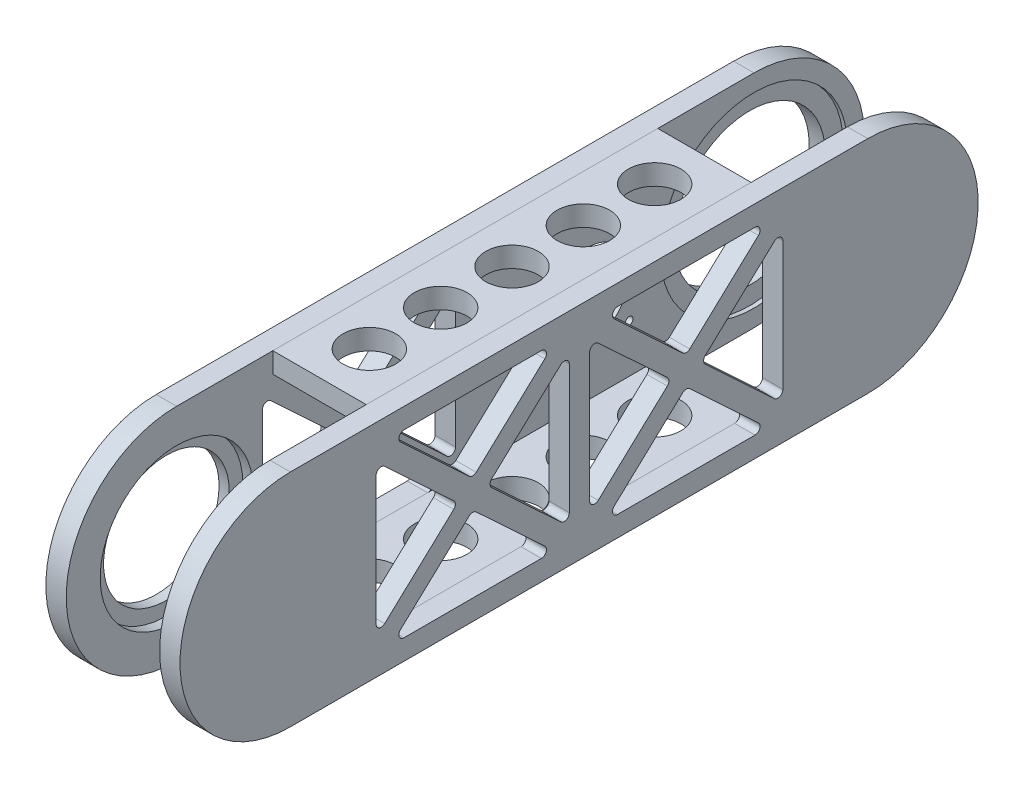
from build123d import *

# Parameters (mm, degrees)
PLATE_REFS_R                    = 44.5
PLATE_REFS_R_2                  = 15
PLATE_REFS_R_3                  = 45
PLATE_REFS_R_4                  = 37
PLATE_REFS_R_5                  = 55
PLATE_SHAPE_DEPTH               = 12
SHOULDER_GEAR_SLOT_START        = 12
PLATE_REFS_4_R                  = 55
PLATE_REFS_4_R_2                = 44.5
SHOULDER_GEAR_SLOT_DEPTH        = 2.5
ELBOW_GEAR_SLOT_START           = 12
PLATE_REFS_5_R                  = 45
ELBOW_GEAR_SLOT_DEPTH           = 6
SKETCH2_R                       = 25
SKETCH2_R_2                     = 2.25
J3_MOTOR_1_DEPTH                = 1
J3_MOTOR_1_DEPTH_BACK           = 13
SKETCH2_3_W                     = 70
SKETCH2_3_H                     = 70
SKETCH2_3_R                     = 25
SKETCH2_3_R_2                   = 2.25
J3_MOTOR_2_DEPTH                = 1
J3_MOTOR_2_DEPTH_BACK           = 6
FILLET1_R                       = 6
TOP_PLATE_START                 = 67
SKETCH3_W                       = 12
SKETCH3_H                       = 226.666666666
TOP_PLATE_DEPTH                 = 55
SIDE_PLATE_2_START              = 67
SIDE_PLATE_2_DEPTH              = 12
SKETCH4_R                       = 14
SIDE_PLATE_BEARING_MOUNTS_DEPTH = 8
PLATE_REFS_7_R                  = 37
CUT_EXTRUDE3_DEPTH              = 8
CUT_EXTRUDE4_DEPTH              = 1
CUT_EXTRUDE4_DEPTH_BACK         = 80
CUT_EXTRUDE5_DEPTH              = 1
CUT_EXTRUDE5_DEPTH_BACK         = 20
SKETCH8_R                       = 15.5
CUT_EXTRUDE6_DEPTH              = 1
CUT_EXTRUDE6_DEPTH_BACK         = 131


with BuildPart() as part:
    # Plate_refs → Plate_shape (new body)
    with BuildSketch(Plane.YZ):
        with BuildLine():
            Line((65, 340), (65, 0))
            ThreePointArc((65, 0), (0, -65), (-65, 0))
            Line((-65, 0), (-65, 340))
            ThreePointArc((-65, 340), (0, 405), (65, 340))
        make_face()
        Circle(PLATE_REFS_R, mode=Mode.SUBTRACT)
        with Locations((0, 340)):
            Circle(PLATE_REFS_R_2, mode=Mode.SUBTRACT)
        with Locations((0, 340)):
            Circle(PLATE_REFS_R_3)
        with Locations((0, 340)):
            Circle(PLATE_REFS_R_4, mode=Mode.SUBTRACT)
        with Locations((0, 340)):
            Circle(PLATE_REFS_R_4)
        with Locations((0, 340)):
            Circle(PLATE_REFS_R_2, mode=Mode.SUBTRACT)
        Circle(PLATE_REFS_R_5)
        Circle(PLATE_REFS_R, mode=Mode.SUBTRACT)
    extrude(amount=PLATE_SHAPE_DEPTH)

    # Plate_refs_4 → Shoulder_gear_slot (cut)
    with BuildSketch(Plane.YZ.offset(SHOULDER_GEAR_SLOT_START)):
        Circle(PLATE_REFS_4_R)
        Circle(PLATE_REFS_4_R_2, mode=Mode.SUBTRACT)
    extrude(amount=-SHOULDER_GEAR_SLOT_DEPTH, mode=Mode.SUBTRACT)

    # Plate_refs_5 → Elbow_gear_slot (cut)
    with BuildSketch(Plane.YZ.offset(ELBOW_GEAR_SLOT_START)):
        with Locations((0, 340)):
            Circle(PLATE_REFS_5_R)
    extrude(amount=-ELBOW_GEAR_SLOT_DEPTH, mode=Mode.SUBTRACT)

    # Sketch2 → J3_motor_1 (cut, two sides)
    with BuildSketch(Plane(origin=(0, 0, 0), x_dir=(0, -1, 0), z_dir=(-1, 0, 0))) as j3_motor_1_sk:
        with Locations((0, 98.247814675)):
            Circle(SKETCH2_R)
        with Locations((-24.748737342, 122.996552017)):
            Circle(SKETCH2_R_2)
        with Locations((24.748737342, 73.499077334)):
            Circle(SKETCH2_R_2)
        with Locations((24.748737342, 122.996552017)):
            Circle(SKETCH2_R_2)
        with Locations((-24.748737342, 73.499077334)):
            Circle(SKETCH2_R_2)
    extrude(amount=J3_MOTOR_1_DEPTH, mode=Mode.SUBTRACT)
    extrude(j3_motor_1_sk.sketch, amount=-J3_MOTOR_1_DEPTH_BACK, mode=Mode.SUBTRACT)

    # Sketch2_3 → J3_motor_2 (cut, two sides)
    with BuildSketch(Plane(origin=(0, 0, 0), x_dir=(0, -1, 0), z_dir=(-1, 0, 0))) as j3_motor_2_sk:
        with Locations((0, 98.247814675)):
            Rectangle(SKETCH2_3_W, SKETCH2_3_H)
        with Locations((0, 98.247814675)):
            Circle(SKETCH2_3_R, mode=Mode.SUBTRACT)
        with Locations((24.748737342, 122.996552017)):
            Circle(SKETCH2_3_R_2, mode=Mode.SUBTRACT)
        with Locations((24.748737342, 73.499077334)):
            Circle(SKETCH2_3_R_2, mode=Mode.SUBTRACT)
        with Locations((-24.748737342, 73.499077334)):
            Circle(SKETCH2_3_R_2, mode=Mode.SUBTRACT)
        with Locations((-24.748737342, 122.996552017)):
            Circle(SKETCH2_3_R_2, mode=Mode.SUBTRACT)
    extrude(amount=J3_MOTOR_2_DEPTH, mode=Mode.SUBTRACT)
    extrude(j3_motor_2_sk.sketch, amount=-J3_MOTOR_2_DEPTH_BACK, mode=Mode.SUBTRACT)

    # Fillet1
    fillet1_edges = [part.edges().sort_by_distance(p)[0] for p in [
        (3, -35, 63.247814675),
        (3, -35, 133.247814675),
        (3, 35, 133.247814675),
        (3, 35, 63.247814675),
    ]]
    fillet(fillet1_edges, radius=FILLET1_R)

    # Plate_refs_7 → Cut-Extrude3 (cut)
    with BuildSketch(Plane.YZ):
        with Locations((0, 340)):
            Circle(PLATE_REFS_7_R)
    extrude(amount=CUT_EXTRUDE3_DEPTH, mode=Mode.SUBTRACT)


with BuildPart() as body_2:
    # Sketch3 → Top_plate (new body)
    with BuildSketch(Plane.YZ.offset(TOP_PLATE_START)):
        with Locations((-59, 170)):
            Rectangle(SKETCH3_W, SKETCH3_H)
    extrude(amount=-TOP_PLATE_DEPTH)


with BuildPart() as body_3:
    # Bottom_plate: mirrored copy
    add(body_2.part.mirror(Plane.ZX))


with BuildPart() as body_4:
    # Plate_refs_6 → Side_plate_2 (new body)
    with BuildSketch(Plane.YZ.offset(SIDE_PLATE_2_START)):
        with BuildLine():
            Line((-65, 340), (-65, 0))
            ThreePointArc((-65, 0), (0, -65), (65, 0))
            Line((65, 0), (65, 340))
            ThreePointArc((65, 340), (0, 405), (-65, 340))
        make_face()
    extrude(amount=SIDE_PLATE_2_DEPTH)

    # Sketch4 → Side_plate_bearing_mounts (cut)
    with BuildSketch(Plane(origin=(67, 0, 0), x_dir=(0, -1, 0), z_dir=(-1, 0, 0))):
        with Locations((0, 340)):
            Circle(SKETCH4_R)
        Circle(SKETCH4_R)
    extrude(amount=-SIDE_PLATE_BEARING_MOUNTS_DEPTH, mode=Mode.SUBTRACT)


with BuildPart() as cut_extrude4_tool:
    # Sketch5 → Cut-Extrude4 (new body, two sides)
    with BuildSketch(Plane(origin=(0, 0, 0), x_dir=(0, -1, 0), z_dir=(-1, 0, 0))) as cut_extrude4_sk:
        with BuildLine():
            Line((-10.106298461, 234.693116547), (-47.805093136, 275.153651137))
            ThreePointArc((-47.805093136, 275.153651137), (-51.098926615, 275.900043345), (-53, 273.108563398))
            Line((-53, 273.108563398), (-53, 192.187494218))
            ThreePointArc((-53, 192.187494218), (-51.098926615, 189.396014271), (-47.805093136, 190.142406479))
            Line((-47.805093136, 190.142406479), (-21.507545379, 218.366461116))
            Line((-21.507545379, 218.366461116), (-10.106298461, 230.602941069))
            ThreePointArc((-10.106298461, 230.602941069), (-9.301205324, 232.648028808), (-10.106298461, 234.693116547))
        make_face()
        with BuildLine():
            ThreePointArc((2.194906864, 243.80530862), (0, 242.850396359), (-2.194906864, 243.80530862))
            Line((-2.194906864, 243.80530862), (-40.098474408, 284.485617338))
            ThreePointArc((-40.098474408, 284.485617338), (-40.654500406, 287.727521016), (-37.903567544, 289.530705077))
            Line((-37.903567544, 289.530705077), (37.903567544, 289.530705077))
            ThreePointArc((37.903567544, 289.530705077), (40.654500406, 287.727521016), (40.098474408, 284.485617338))
            Line((40.098474408, 284.485617338), (2.194906864, 243.80530862))
        make_face()
        with BuildLine():
            ThreePointArc((47.805093136, 275.153651137), (51.098926615, 275.900043345), (53, 273.108563398))
            Line((53, 273.108563398), (53, 192.187494218))
            ThreePointArc((53, 192.187494218), (51.098926615, 189.396014271), (47.805093136, 190.142406479))
            Line((47.805093136, 190.142406479), (10.106298461, 230.602941069))
            ThreePointArc((10.106298461, 230.602941069), (9.301205324, 232.648028808), (10.106298461, 234.693116547))
            Line((10.106298461, 234.693116547), (47.805093136, 275.153651137))
        make_face()
        with BuildLine():
            ThreePointArc((40.098474408, 180.810440277), (40.654500406, 177.5685366), (37.903567544, 175.765352539))
            Line((37.903567544, 175.765352539), (-37.903567544, 175.765352539))
            ThreePointArc((-37.903567544, 175.765352539), (-40.654500406, 177.5685366), (-40.098474408, 180.810440277))
            Line((-40.098474408, 180.810440277), (-2.194906864, 221.490748996))
            ThreePointArc((-2.194906864, 221.490748996), (0, 222.445661257), (2.194906864, 221.490748996))
            Line((2.194906864, 221.490748996), (40.098474408, 180.810440277))
        make_face()
    extrude(amount=CUT_EXTRUDE4_DEPTH)
    extrude(cut_extrude4_sk.sketch, amount=-CUT_EXTRUDE4_DEPTH_BACK)


with BuildPart() as part_1:
    add(part.part)

    # Cut-Extrude4: cut by cut_extrude4_tool
    add(cut_extrude4_tool.part, mode=Mode.SUBTRACT)


with BuildPart() as body_4_1:
    add(body_4.part)

    # Cut-Extrude4: cut by cut_extrude4_tool
    add(cut_extrude4_tool.part, mode=Mode.SUBTRACT)

    # Sketch7 → Cut-Extrude5 (cut, two sides)
    with BuildSketch(Plane.YZ.offset(79)) as cut_extrude5_sk:
        with BuildLine():
            Line((10.106298461, 104.837588531), (47.805093136, 64.37705394))
            ThreePointArc((47.805093136, 64.37705394), (51.098926615, 63.630661732), (53, 66.422141679))
            Line((53, 66.422141679), (53, 147.343210859))
            ThreePointArc((53, 147.343210859), (51.098926615, 150.134690807), (47.805093136, 149.388298598))
            Line((47.805093136, 149.388298598), (21.507545379, 121.164243962))
            Line((21.507545379, 121.164243962), (10.106298461, 108.927764008))
            ThreePointArc((10.106298461, 108.927764008), (9.301205324, 106.882676269), (10.106298461, 104.837588531))
        make_face()
        with BuildLine():
            Line((37.903567544, 50), (-37.903567544, 50))
            ThreePointArc((-37.903567544, 50), (-40.654500406, 51.803184061), (-40.098474408, 55.045087739))
            Line((-40.098474408, 55.045087739), (-2.194906864, 95.725396457))
            ThreePointArc((-2.194906864, 95.725396457), (0, 96.680308719), (2.194906864, 95.725396457))
            Line((2.194906864, 95.725396457), (40.098474408, 55.045087739))
            ThreePointArc((40.098474408, 55.045087739), (40.654500406, 51.803184061), (37.903567544, 50))
        make_face()
        with BuildLine():
            Line((-10.106298461, 104.837588531), (-47.805093136, 64.37705394))
            ThreePointArc((-47.805093136, 64.37705394), (-51.098926615, 63.630661732), (-53, 66.422141679))
            Line((-53, 66.422141679), (-53, 147.343210859))
            ThreePointArc((-53, 147.343210859), (-51.098926615, 150.134690807), (-47.805093136, 149.388298598))
            Line((-47.805093136, 149.388298598), (-10.106298461, 108.927764008))
            ThreePointArc((-10.106298461, 108.927764008), (-9.301205324, 106.882676269), (-10.106298461, 104.837588531))
        make_face()
        with BuildLine():
            Line((-40.098474408, 158.7202648), (-2.194906864, 118.039956081))
            ThreePointArc((-2.194906864, 118.039956081), (0, 117.08504382), (2.194906864, 118.039956081))
            Line((2.194906864, 118.039956081), (40.098474408, 158.7202648))
            ThreePointArc((40.098474408, 158.7202648), (40.654500406, 161.962168478), (37.903567544, 163.765352539))
            Line((37.903567544, 163.765352539), (-37.903567544, 163.765352539))
            ThreePointArc((-37.903567544, 163.765352539), (-40.654500406, 161.962168478), (-40.098474408, 158.7202648))
        make_face()
    extrude(amount=CUT_EXTRUDE5_DEPTH, mode=Mode.SUBTRACT)
    extrude(cut_extrude5_sk.sketch, amount=-CUT_EXTRUDE5_DEPTH_BACK, mode=Mode.SUBTRACT)


with BuildPart() as cut_extrude6_tool:
    # Sketch8 → Cut-Extrude6 (new body, two sides)
    with BuildSketch(Plane.XZ.offset(65)) as cut_extrude6_sk:
        with Locations((39.5, 170)):
            Circle(SKETCH8_R)
        with Locations((39.5, 128)):
            Circle(SKETCH8_R)
        with Locations((39.5, 86)):
            Circle(SKETCH8_R)
        with Locations((39.5, 254)):
            Circle(SKETCH8_R)
        with Locations((39.5, 212)):
            Circle(SKETCH8_R)
    extrude(amount=CUT_EXTRUDE6_DEPTH)
    extrude(cut_extrude6_sk.sketch, amount=-CUT_EXTRUDE6_DEPTH_BACK)


with BuildPart() as body_2_1:
    add(body_2.part)

    # Cut-Extrude6: cut by cut_extrude6_tool
    add(cut_extrude6_tool.part, mode=Mode.SUBTRACT)


with BuildPart() as body_3_1:
    add(body_3.part)

    # Cut-Extrude6: cut by cut_extrude6_tool
    add(cut_extrude6_tool.part, mode=Mode.SUBTRACT)


solid = Compound([part_1.part, body_4_1.part, body_2_1.part, body_3_1.part])
